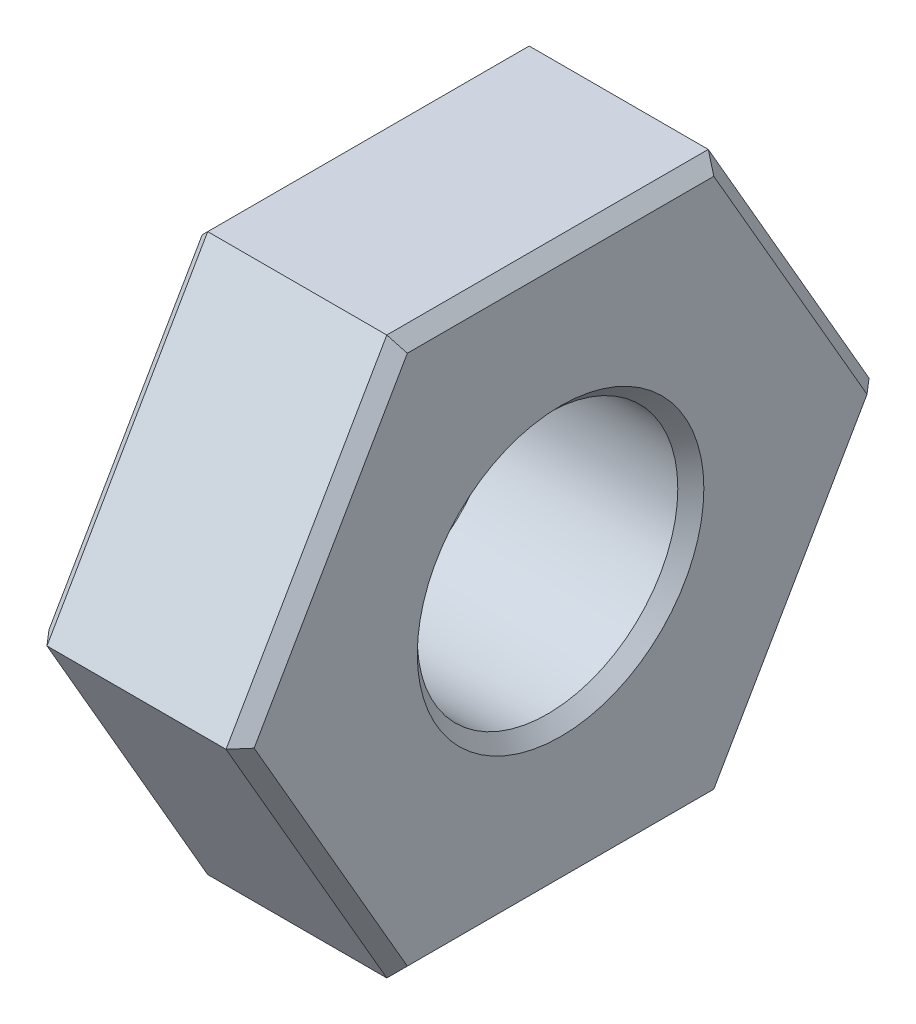
from build123d import *

# Parameters (mm, degrees)
BOSS_EXTRUDE3_DEPTH = 3.15
SKETCH3_R           = 2
CUT_EXTRUDE2_DEPTH  = 7
CHAMFER1_SIZE       = 0.2


with BuildPart() as part:
    # Sketch2 → Boss-Extrude3 (new body)
    with BuildSketch(Plane(origin=(0, 0, 0), x_dir=(0, 0, -1), z_dir=(1, 0, 0))):
        Polygon((4.936344802, 0), (2.468172401, 4.275), (-2.468172401, 4.275), (-4.936344802, 0), (-2.468172401, -4.275), (2.468172401, -4.275), align=None)
    extrude(amount=BOSS_EXTRUDE3_DEPTH)

    # Sketch3 → Cut-Extrude2 (cut)
    with BuildSketch(Plane(origin=(3.15, 0, 0), x_dir=(0, 0, -1), z_dir=(1, 0, 0))):
        Circle(SKETCH3_R)
    extrude(amount=-CUT_EXTRUDE2_DEPTH, mode=Mode.SUBTRACT)

    # Chamfer1
    chamfer1_edges = [part.edges().sort_by_distance(p)[0] for p in [
        (3.15, 4.275, 0),
        (3.15, 2.1375, 3.702258601),
        (3.15, -2.1375, 3.702258601),
        (3.15, -4.275, 0),
        (0, 0, 2),
        (3.15, 0, 2),
        (3.15, -2.1375, -3.702258601),
        (0, -4.275, 0),
        (0, -2.1375, 3.702258601),
        (0, 2.1375, 3.702258601),
        (3.15, 2.1375, -3.702258601),
        (0, 4.275, 0),
        (0, 2.1375, -3.702258601),
        (0, -2.1375, -3.702258601),
    ]]
    chamfer(chamfer1_edges, length=CHAMFER1_SIZE)


solid = part.part
